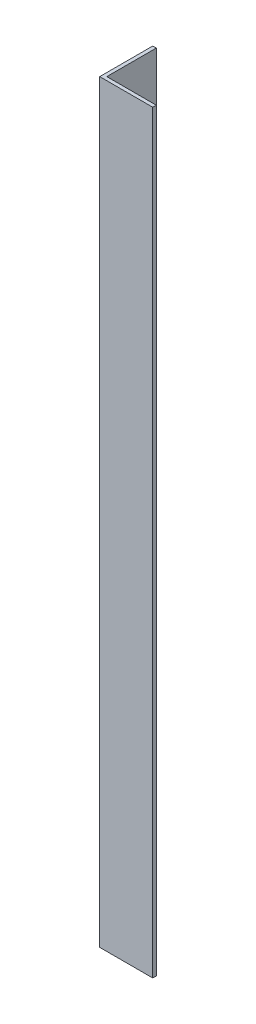
from build123d import *

# Parameters (mm, degrees)
EXTRUDE_1_DEPTH = 640


with BuildPart() as part:
    # Эскиз1 → Вытянуть-Тонкостенный1 (new body)
    with BuildSketch(Plane(origin=(0, 0, 0), x_dir=(1, 0, 0), z_dir=(0, 1, 0))):
        Polygon((0, 45), (0, 0), (45, 0), (45, 3), (3, 3), (3, 45), align=None)
    extrude(amount=EXTRUDE_1_DEPTH)


solid = part.part
